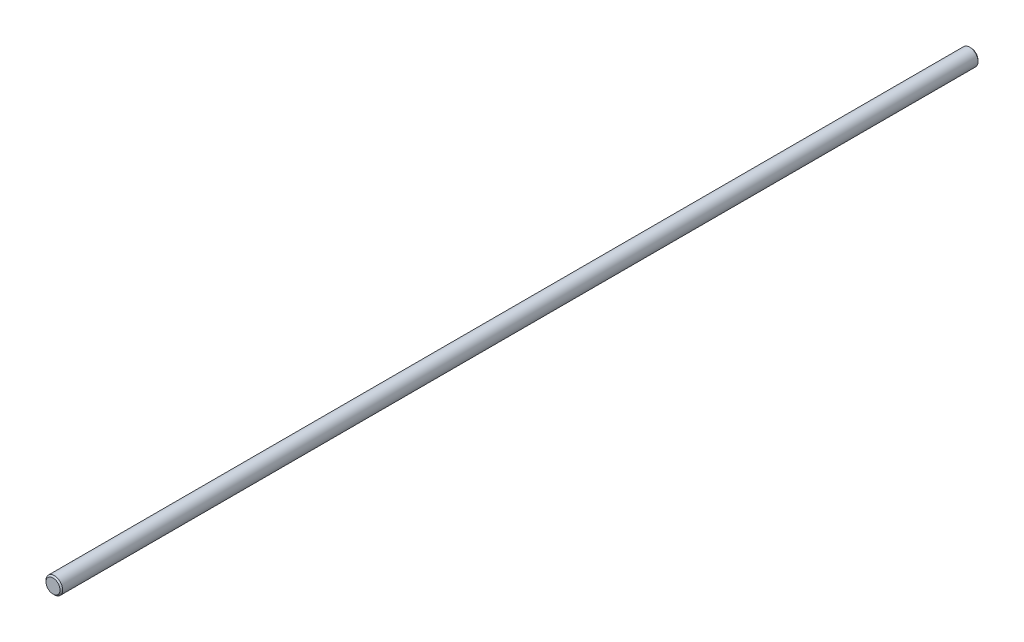
from build123d import *

# Parameters (mm, degrees)
SKETCH1_R           = 3.175
BOSS_EXTRUDE1_DEPTH = 349.25
CHAMFER1_SIZE       = 0.508


with BuildPart() as part:
    # Sketch1 → Boss-Extrude1 (new body)
    with BuildSketch(Plane.XY):
        Circle(SKETCH1_R)
    extrude(amount=BOSS_EXTRUDE1_DEPTH)

    # Chamfer1
    chamfer1_edges = [part.edges().sort_by_distance(p)[0] for p in [
        (-3.175, 0, 0),
        (-3.175, 0, 349.25),
    ]]
    chamfer(chamfer1_edges, length=CHAMFER1_SIZE)


solid = part.part
